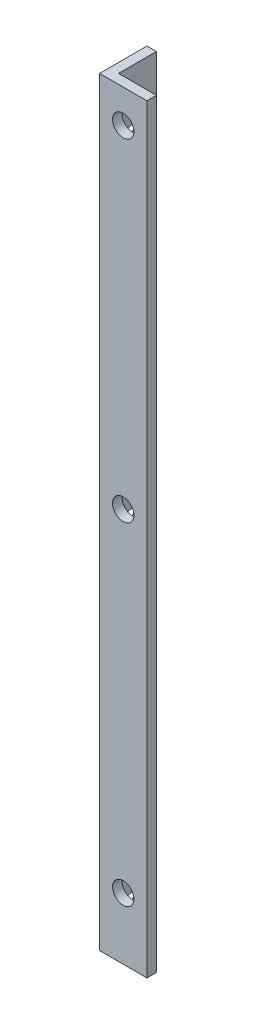
from build123d import *

# Parameters (mm, degrees)
EXTRUDE_1_DEPTH     = 160
CUT_EXTRUDE_1_REACH = 12
SKETCH_2_R          = 2.25
CUT_EXTRUDE_2_REACH = 12
SKETCH_3_R          = 2.25


with BuildPart() as part:
    # Эскиз1 → Бобышка-Вытянуть1 (new body)
    with BuildSketch(Plane(origin=(0, 0, 0), x_dir=(1, 0, 0), z_dir=(0, 1, 0))):
        Polygon((0, 10), (0, 0), (10, 0), (10, 2), (2, 2), (2, 10), align=None)
    extrude(amount=EXTRUDE_1_DEPTH)

    # Эскиз2 → Вырез-Вытянуть1 (cut, up to next)
    with BuildSketch(Plane.XY, mode=Mode.PRIVATE) as cut_extrude_1_sk1:
        with Locations((5, 13)):
            Circle(SKETCH_2_R)
    cut_extrude_1_tool1 = extrude(cut_extrude_1_sk1.sketch, amount=-CUT_EXTRUDE_1_REACH, mode=Mode.PRIVATE) & part.part
    add(cut_extrude_1_tool1.solids().sort_by_distance((5, 13, 0))[0], mode=Mode.SUBTRACT)
    # Эскиз2 → Вырез-Вытянуть1 (cut, up to next)
    with BuildSketch(Plane.XY, mode=Mode.PRIVATE) as cut_extrude_1_sk2:
        with Locations((5, 83)):
            Circle(SKETCH_2_R)
    cut_extrude_1_tool2 = extrude(cut_extrude_1_sk2.sketch, amount=-CUT_EXTRUDE_1_REACH, mode=Mode.PRIVATE) & part.part
    add(cut_extrude_1_tool2.solids().sort_by_distance((5, 83, 0))[0], mode=Mode.SUBTRACT)
    # Эскиз2 → Вырез-Вытянуть1 (cut, up to next)
    with BuildSketch(Plane.XY, mode=Mode.PRIVATE) as cut_extrude_1_sk3:
        with Locations((5, 153)):
            Circle(SKETCH_2_R)
    cut_extrude_1_tool3 = extrude(cut_extrude_1_sk3.sketch, amount=-CUT_EXTRUDE_1_REACH, mode=Mode.PRIVATE) & part.part
    add(cut_extrude_1_tool3.solids().sort_by_distance((5, 153, 0))[0], mode=Mode.SUBTRACT)

    # Эскиз3 → Вырез-Вытянуть2 (cut, up to next)
    with BuildSketch(Plane.ZY, mode=Mode.PRIVATE) as cut_extrude_2_sk1:
        with Locations((-5, 7)):
            Circle(SKETCH_3_R)
    cut_extrude_2_tool1 = extrude(cut_extrude_2_sk1.sketch, amount=-CUT_EXTRUDE_2_REACH, mode=Mode.PRIVATE) & part.part
    add(cut_extrude_2_tool1.solids().sort_by_distance((0, 7, -5))[0], mode=Mode.SUBTRACT)
    # Эскиз3 → Вырез-Вытянуть2 (cut, up to next)
    with BuildSketch(Plane.ZY, mode=Mode.PRIVATE) as cut_extrude_2_sk2:
        with Locations((-5, 77)):
            Circle(SKETCH_3_R)
    cut_extrude_2_tool2 = extrude(cut_extrude_2_sk2.sketch, amount=-CUT_EXTRUDE_2_REACH, mode=Mode.PRIVATE) & part.part
    add(cut_extrude_2_tool2.solids().sort_by_distance((0, 77, -5))[0], mode=Mode.SUBTRACT)
    # Эскиз3 → Вырез-Вытянуть2 (cut, up to next)
    with BuildSketch(Plane.ZY, mode=Mode.PRIVATE) as cut_extrude_2_sk3:
        with Locations((-5, 147)):
            Circle(SKETCH_3_R)
    cut_extrude_2_tool3 = extrude(cut_extrude_2_sk3.sketch, amount=-CUT_EXTRUDE_2_REACH, mode=Mode.PRIVATE) & part.part
    add(cut_extrude_2_tool3.solids().sort_by_distance((0, 147, -5))[0], mode=Mode.SUBTRACT)


solid = part.part
